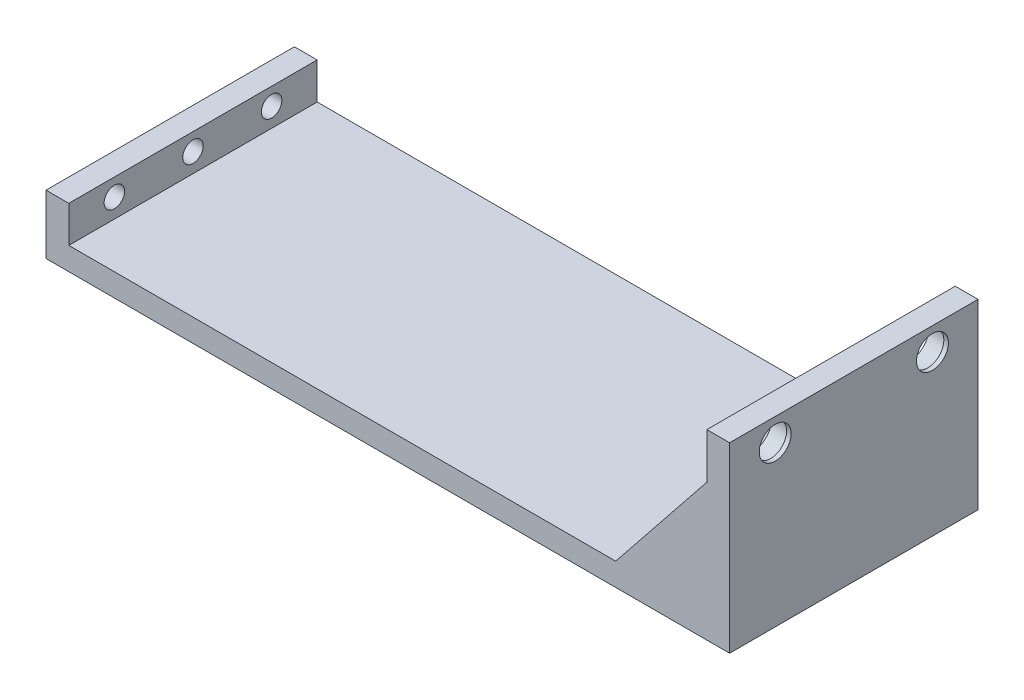
from build123d import *

# Parameters (mm, degrees)
SKETCH1_W                 = 150
SKETCH1_H                 = 54.5
BOSS_EXTRUDE1_DEPTH       = 5
SKETCH2_W                 = 5
SKETCH2_H                 = 54.5
BOSS_EXTRUDE2_DEPTH       = 8
F_8_CLEARANCE_HOLE1_D     = 4.4958
F_8_CLEARANCE_HOLE1_DEPTH = 17
F_8_CLEARANCE_HOLE1_TIP   = 1.350674586
SKETCH7_W                 = 5
SKETCH7_H                 = 54.5
BOSS_EXTRUDE3_DEPTH       = 35
SKETCH8_R                 = 4.25
CUT_EXTRUDE1_DEPTH        = 4
RIB1_REACH                = 117.066
SKETCH10_WALL_W           = 264.147591324
SKETCH10_WALL_H           = 10
RIB3_REACH                = 117.066
SKETCH12_WALL_W           = 264.147591324
SKETCH12_WALL_H           = 10
SKETCH13_W                = 8
SKETCH13_H                = 2
BOSS_EXTRUDE4_DEPTH       = 5
SKETCH14_R                = 2
CUT_EXTRUDE2_DEPTH        = 2
SKETCH15_R                = 3.5
CUT_EXTRUDE3_DEPTH        = 1


with BuildPart() as part:
    # Sketch1 → Boss-Extrude1 (new body)
    with BuildSketch(Plane(origin=(0, 0, 0), x_dir=(1, 0, 0), z_dir=(0, 1, 0))):
        with Locations((-18.112463826, -1.689393939)):
            Rectangle(SKETCH1_W, SKETCH1_H)
    extrude(amount=BOSS_EXTRUDE1_DEPTH)

    # Sketch2 → Boss-Extrude2 (add)
    with BuildSketch(Plane(origin=(0, 5, 0), x_dir=(1, 0, 0), z_dir=(0, 1, 0))):
        with Locations((-90.612463826, -1.689393939)):
            Rectangle(SKETCH2_W, SKETCH2_H)
    extrude(amount=BOSS_EXTRUDE2_DEPTH)

    # #8 Clearance Hole1
    with Locations(Plane(origin=(-93.112463826, 9.2, -15.560606061), x_dir=(0, 0, -1), z_dir=(-1, 0, 0))):
        with Locations((0, 0), (-17.25, 0), (-34.5, 0)):
            Hole(F_8_CLEARANCE_HOLE1_D / 2, depth=F_8_CLEARANCE_HOLE1_DEPTH)
            with Locations((0, 0, -(F_8_CLEARANCE_HOLE1_DEPTH + F_8_CLEARANCE_HOLE1_TIP / 2))):  # 118° drill point
                Cone(0, F_8_CLEARANCE_HOLE1_D / 2, F_8_CLEARANCE_HOLE1_TIP, mode=Mode.SUBTRACT)

    # Sketch7 → Boss-Extrude3 (add)
    with BuildSketch(Plane(origin=(0, 5, 0), x_dir=(1, 0, 0), z_dir=(0, 1, 0))):
        with Locations((54.387536174, -1.689393939)):
            Rectangle(SKETCH7_W, SKETCH7_H)
    extrude(amount=BOSS_EXTRUDE3_DEPTH)

    # Sketch8 → Cut-Extrude1 (cut)
    with BuildSketch(Plane.ZY.offset(-51.887536174)):
        with Locations((-15.560606061, 35)):
            Circle(SKETCH8_R)
        with Locations((18.939393939, 35)):
            Circle(SKETCH8_R)
    extrude(amount=-CUT_EXTRUDE1_DEPTH, mode=Mode.SUBTRACT)

    # Sketch10 wall → Rib1 (add, up to next)
    with BuildSketch(Plane(origin=(41.887536174, 17.5, -25.560606061), x_dir=(-0.624695047554, -0.780868809443, 0), z_dir=(-0.780868809443, 0.624695047554, 0)), mode=Mode.PRIVATE) as rib1_sk1:
        with Locations((0, 5)):
            Rectangle(SKETCH10_WALL_W, SKETCH10_WALL_H)
    rib1_tool1 = extrude(rib1_sk1.sketch, amount=-RIB1_REACH, mode=Mode.PRIVATE) - part.part
    add(rib1_tool1.solids().sort_by_distance((41.887536174, 17.5, -25.560606061))[0])

    # Sketch12 wall → Rib3 (add, up to next)
    with BuildSketch(Plane(origin=(41.887536174, 17.5, 28.939393939), x_dir=(-0.624695047554, -0.780868809443, 0), z_dir=(0.780868809443, -0.624695047554, 0)), mode=Mode.PRIVATE) as rib3_sk1:
        with Locations((0, 5)):
            Rectangle(SKETCH12_WALL_W, SKETCH12_WALL_H)
    rib3_tool1 = extrude(rib3_sk1.sketch, amount=RIB3_REACH, mode=Mode.PRIVATE) - part.part
    add(rib3_tool1.solids().sort_by_distance((41.887536174, 17.5, 28.939393939))[0])

    # Sketch13 → Boss-Extrude4 (add)
    with BuildSketch(Plane.ZY.offset(-51.887536174)):
        with Locations((1.689393939, 29)):
            Rectangle(SKETCH13_W, SKETCH13_H)
    extrude(amount=BOSS_EXTRUDE4_DEPTH)

    # Sketch14 → Cut-Extrude2 (cut)
    with BuildSketch(Plane(origin=(0, 30, 0), x_dir=(1, 0, 0), z_dir=(0, 1, 0))):
        with Locations(Location((49.387536174, -1.689393939, 0), (0, 0, 270))):
            Circle(SKETCH14_R)
    extrude(amount=-CUT_EXTRUDE2_DEPTH, mode=Mode.SUBTRACT)

    # Sketch15 → Cut-Extrude3 (cut)
    with BuildSketch(Plane.ZY.offset(-55.887536174)):
        with Locations((-15.560606061, 35)):
            Circle(SKETCH15_R)
        with Locations((18.939393939, 35)):
            Circle(SKETCH15_R)
    extrude(amount=-CUT_EXTRUDE3_DEPTH, mode=Mode.SUBTRACT)


solid = part.part
